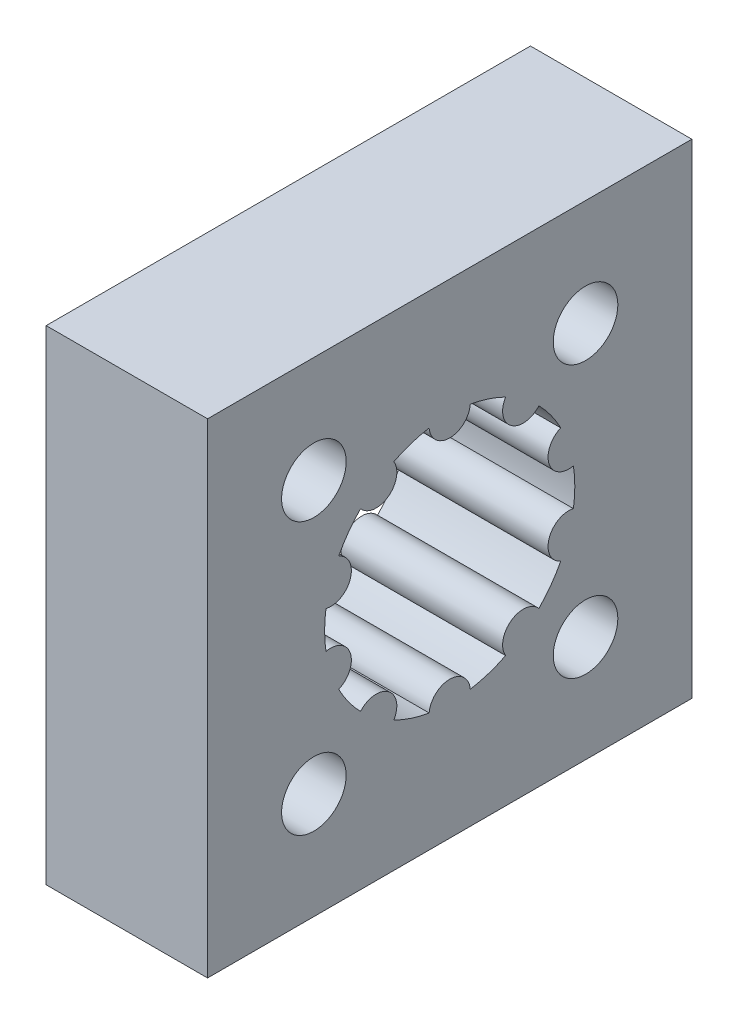
from build123d import *

# Parameters (mm, degrees)
SKETCH1_W           = 30
SKETCH1_H           = 30
SKETCH1_R           = 2
BOSS_EXTRUDE1_DEPTH = 10


with BuildPart() as part:
    # Sketch1 → Boss-Extrude1 (new body)
    with BuildSketch(Plane(origin=(0, 0, 0), x_dir=(0, 0, -1), z_dir=(1, 0, 0))):
        Rectangle(SKETCH1_W, SKETCH1_H)
        with Locations((8.414570696, 8.414570696)):
            Circle(SKETCH1_R, mode=Mode.SUBTRACT)
        with Locations((8.414570696, -8.414570696)):
            Circle(SKETCH1_R, mode=Mode.SUBTRACT)
        with Locations((-8.414570696, -8.414570696)):
            Circle(SKETCH1_R, mode=Mode.SUBTRACT)
        with Locations((-8.414570696, 8.414570696)):
            Circle(SKETCH1_R, mode=Mode.SUBTRACT)
        with BuildLine():
            ThreePointArc((-1.274653828, 7.644459276), (0, 6.470984275), (1.274653828, 7.644459276))
            ThreePointArc((1.274653828, 7.644459276), (2.394881706, 7.370688001), (3.462083815, 6.933720189))
            ThreePointArc((3.462083815, 6.933720189), (3.803549125, 5.235136249), (5.524517033, 5.435274745))
            ThreePointArc((5.524517033, 5.435274745), (6.269881706, 4.555335705), (6.876423113, 3.574535658))
            ThreePointArc((6.876423113, 3.574535658), (6.154271761, 1.999644111), (7.664202503, 1.15))
            ThreePointArc((7.664202503, 1.15), (7.75, 0), (7.664202503, -1.15))
            ThreePointArc((7.664202503, -1.15), (6.154271761, -1.999644111), (6.876423113, -3.574535658))
            ThreePointArc((6.876423113, -3.574535658), (6.269881706, -4.555335705), (5.524517033, -5.435274745))
            ThreePointArc((5.524517033, -5.435274745), (3.803549125, -5.235136249), (3.462083815, -6.933720189))
            ThreePointArc((3.462083815, -6.933720189), (2.394881706, -7.370688001), (1.274653828, -7.644459276))
            ThreePointArc((1.274653828, -7.644459276), (0, -6.470984275), (-1.274653828, -7.644459276))
            ThreePointArc((-1.274653828, -7.644459276), (-2.394881706, -7.370688001), (-3.462083815, -6.933720189))
            ThreePointArc((-3.462083815, -6.933720189), (-3.803549125, -5.235136249), (-5.524517033, -5.435274745))
            ThreePointArc((-5.524517033, -5.435274745), (-6.269881706, -4.555335705), (-6.876423113, -3.574535658))
            ThreePointArc((-6.876423113, -3.574535658), (-6.154271761, -1.999644111), (-7.664202503, -1.15))
            ThreePointArc((-7.664202503, -1.15), (-7.75, 0), (-7.664202503, 1.15))
            ThreePointArc((-7.664202503, 1.15), (-6.154271761, 1.999644111), (-6.876423113, 3.574535658))
            ThreePointArc((-6.876423113, 3.574535658), (-6.269881706, 4.555335705), (-5.524517033, 5.435274745))
            ThreePointArc((-5.524517033, 5.435274745), (-3.803549125, 5.235136249), (-3.462083815, 6.933720189))
            ThreePointArc((-3.462083815, 6.933720189), (-2.394881706, 7.370688001), (-1.274653828, 7.644459276))
        make_face(mode=Mode.SUBTRACT)
    extrude(amount=BOSS_EXTRUDE1_DEPTH)


solid = part.part
